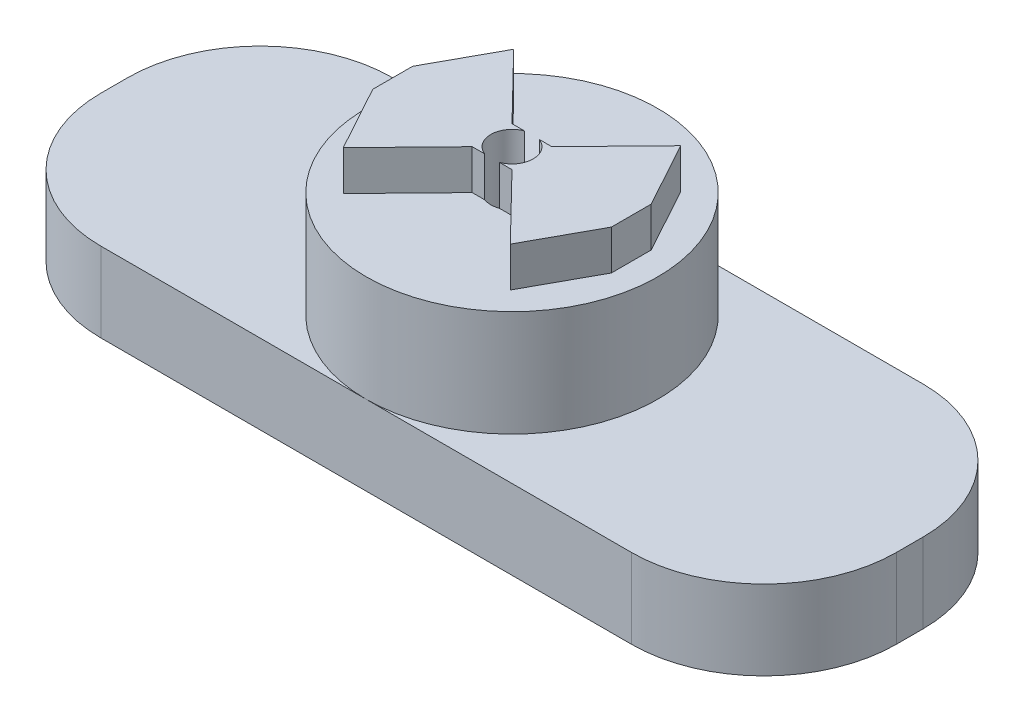
from build123d import *

# Parameters (mm, degrees)
BOSS_EXTRUDE1_DEPTH                                 = 6
SKETCH2_R                                           = 11
BOSS_EXTRUDE2_DEPTH                                 = 8
SKETCH12_R                                          = 6
CUT_EXTRUDE2_DEPTH                                  = 4
BOSS_EXTRUDE3_DEPTH                                 = 3
CSK_FOR_M3_COUNTERSUNK_FLAT_HEAD_SCREW3_D           = 3.2
CSK_FOR_M3_COUNTERSUNK_FLAT_HEAD_SCREW3_CSINK_D     = 6.3
CSK_FOR_M3_COUNTERSUNK_FLAT_HEAD_SCREW3_CSINK_ANGLE = 90
CUT_EXTRUDE3_DEPTH                                  = 1


with BuildPart() as part:
    # Sketch1 → Boss-Extrude1 (new body)
    with BuildSketch(Plane(origin=(0, 0, 0), x_dir=(1, 0, 0), z_dir=(0, 1, 0))):
        with BuildLine():
            Line((-20.01, -11), (20.01, -11))
            ThreePointArc((20.01, -11), (27.073996744, -8.073996744), (30, -1.01))
            Line((30, -1.01), (30, 1.01))
            ThreePointArc((30, 1.01), (27.073996744, 8.073996744), (20.01, 11))
            Line((20.01, 11), (-20.01, 11))
            ThreePointArc((-20.01, 11), (-27.073996744, 8.073996744), (-30, 1.01))
            Line((-30, 1.01), (-30, -1.01))
            ThreePointArc((-30, -1.01), (-27.073996744, -8.073996744), (-20.01, -11))
        make_face()
    extrude(amount=BOSS_EXTRUDE1_DEPTH)

    # Sketch2 → Boss-Extrude2 (add)
    with BuildSketch(Plane(origin=(0, 6, 0), x_dir=(1, 0, 0), z_dir=(0, 1, 0))):
        Circle(SKETCH2_R)
    extrude(amount=BOSS_EXTRUDE2_DEPTH)

    # Sketch12 → Cut-Extrude2 (cut)
    with BuildSketch(Plane.XZ):
        Circle(SKETCH12_R)
    extrude(amount=-CUT_EXTRUDE2_DEPTH, mode=Mode.SUBTRACT)

    # Sketch19 → Boss-Extrude3 (add)
    with BuildSketch(Plane(origin=(0, 14, 0), x_dir=(1, 0, 0), z_dir=(0, 1, 0))):
        Polygon((-6.300393599, 6.426899758), (-9, 1.5), (-9, -1.5), (-6.300393599, -6.426899758), (-1.5, -1.5), (1.5, -1.5), (6.300393599, -6.426899758), (9, -1.5), (9, 1.5), (6.300393599, 6.426899758), (1.5, 1.5), (-1.5, 1.5), align=None)
    extrude(amount=BOSS_EXTRUDE3_DEPTH)

    # CSK for M3 Countersunk Flat Head Screw3 (through all)
    with Locations(Plane(origin=(0, 4, 0), x_dir=(-1, 0, 0), z_dir=(0, -1, 0))):
        with Locations((0, 0)):
            CounterSinkHole(CSK_FOR_M3_COUNTERSUNK_FLAT_HEAD_SCREW3_D / 2, CSK_FOR_M3_COUNTERSUNK_FLAT_HEAD_SCREW3_CSINK_D / 2, counter_sink_angle=CSK_FOR_M3_COUNTERSUNK_FLAT_HEAD_SCREW3_CSINK_ANGLE)

    # Sketch20 → Cut-Extrude3 (cut)
    with BuildSketch(Plane.XZ):
        Polygon((10, 2.5), (10, -2.5), (20, -2.5), (20, -6), (26, 0), (20, 6), (20, 2.5), align=None)
    extrude(amount=-CUT_EXTRUDE3_DEPTH, mode=Mode.SUBTRACT)


solid = part.part
